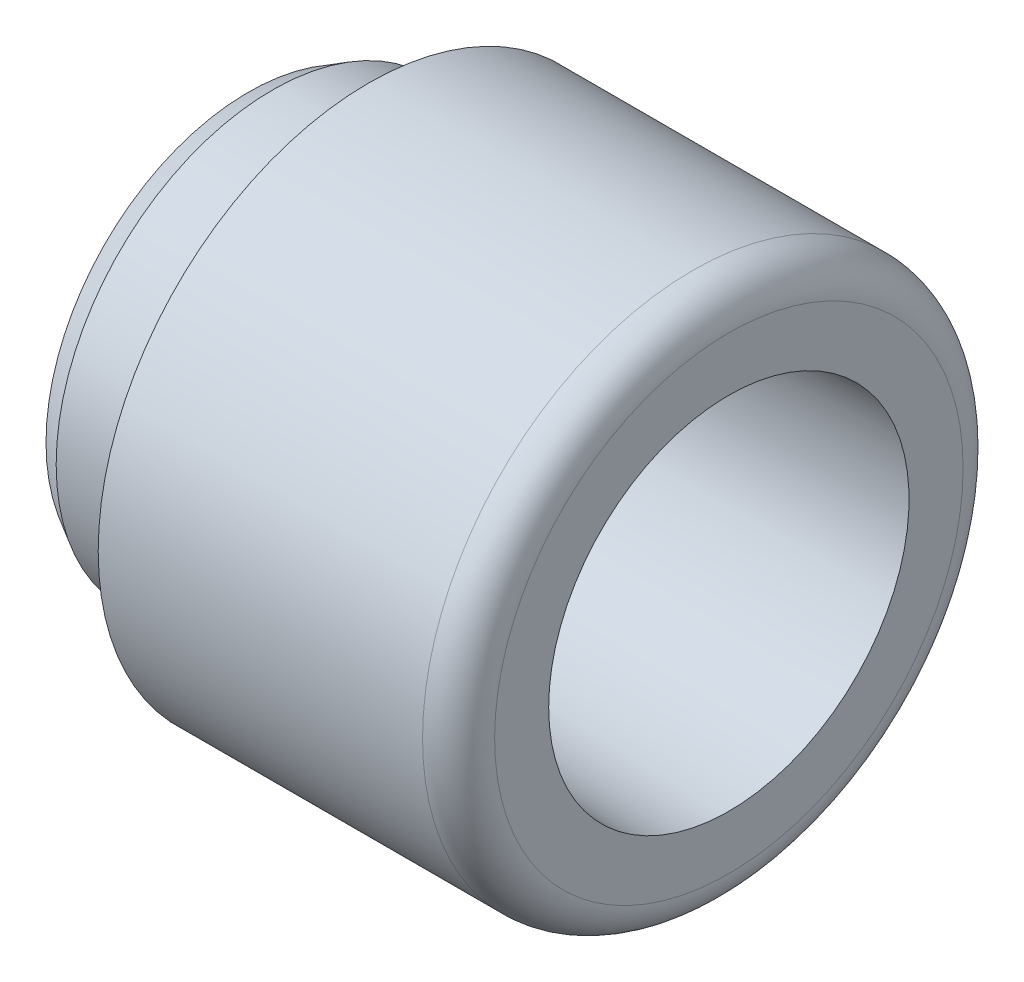
from build123d import *


with BuildPart() as part:
    # Sketch1 → Revolve1 (revolve)
    with BuildSketch(Plane.XY):
        with BuildLine():
            Line((0, 16.845299462), (2, 18))
            Line((2, 18), (10, 18))
            Line((10, 18), (10, 22.5))
            Line((10, 22.5), (37, 22.5))
            ThreePointArc((37, 22.5), (39.121320344, 21.621320344), (40, 19.5))
            Line((40, 19.5), (40, 15))
            Line((40, 15), (12.772080403, 14.049180096))
            ThreePointArc((12.772080403, 14.049180096), (12.22452816, 13.805394131), (12, 13.249667434))
            Line((12, 13.249667434), (12, 5.1))
            Line((12, 5.1), (0, 5.1))
            Line((0, 5.1), (0, 16.845299462))
        make_face()
    revolve(axis=Axis((0, 0, 0), (1, 0, 0)))


solid = part.part
